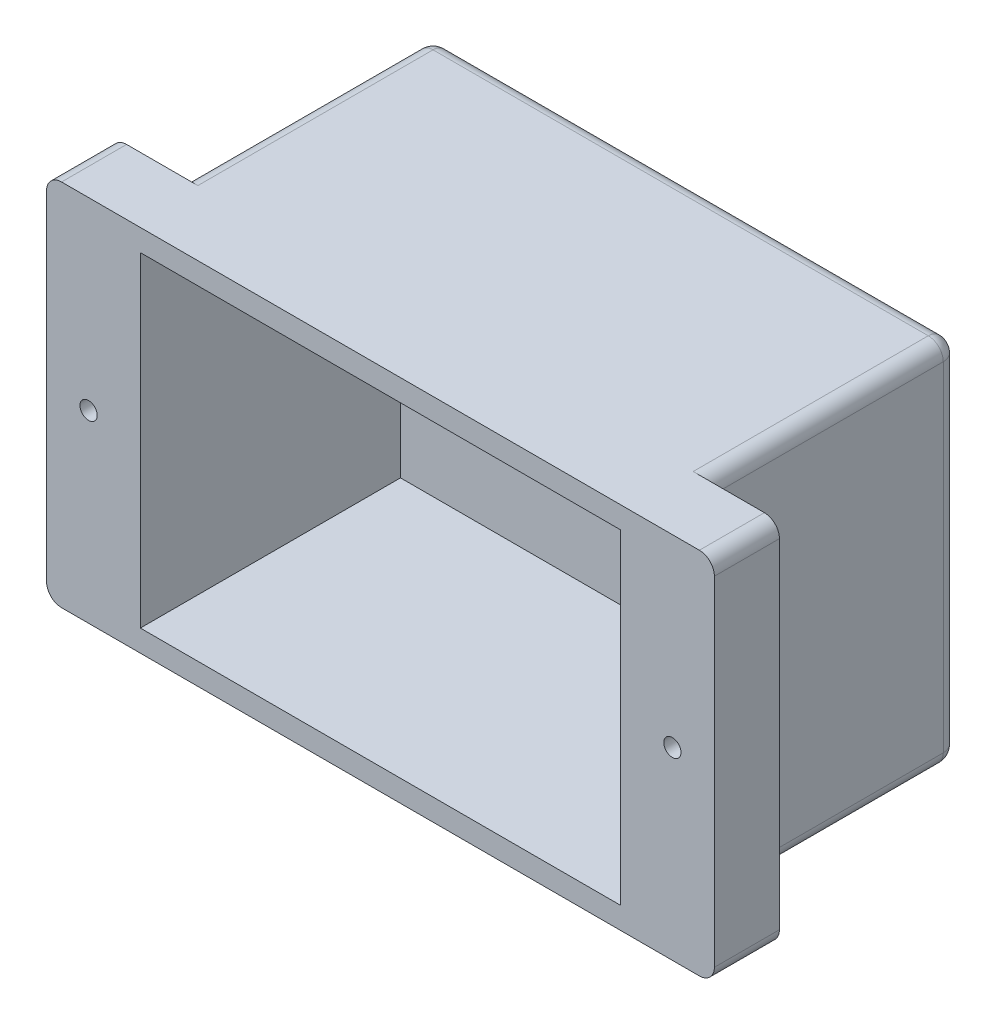
from build123d import *

# Parameters (mm, degrees)
SKETCH1_W                = 133.5
SKETCH1_H                = 73.7
SKETCH1_R                = 1.725
BOSS_EXTRUDE1_DEPTH      = 7.5
BOSS_EXTRUDE1_DEPTH_BACK = 5.5
SKETCH2_W                = 105
SKETCH2_H                = 73.7
BOSS_EXTRUDE2_DEPTH      = 50
SKETCH6_W                = 96
SKETCH6_H                = 65
CUT_EXTRUDE3_DEPTH       = 52
FILLET5_R                = 3
FILLET6_R                = 3


with BuildPart() as part:
    # Sketch1 → Boss-Extrude1 (new body, two sides)
    with BuildSketch(Plane.XY) as boss_extrude1_sk:
        Rectangle(SKETCH1_W, SKETCH1_H)
        with Locations((-58.35, 0)):
            Circle(SKETCH1_R, mode=Mode.SUBTRACT)
        with Locations((58.35, 0)):
            Circle(SKETCH1_R, mode=Mode.SUBTRACT)
    extrude(amount=BOSS_EXTRUDE1_DEPTH)
    extrude(boss_extrude1_sk.sketch, amount=-BOSS_EXTRUDE1_DEPTH_BACK)

    # Sketch2 → Boss-Extrude2 (add)
    with BuildSketch(Plane(origin=(0, 0, -5.5), x_dir=(-1, 0, 0), z_dir=(0, 0, -1))):
        Rectangle(SKETCH2_W, SKETCH2_H)
    extrude(amount=BOSS_EXTRUDE2_DEPTH)

    # Sketch6 → Cut-Extrude3 (cut)
    with BuildSketch(Plane.XY.offset(7.5)):
        Rectangle(SKETCH6_W, SKETCH6_H)
    extrude(amount=-CUT_EXTRUDE3_DEPTH, mode=Mode.SUBTRACT)

    # Fillet5
    fillet5_edges = [part.edges().sort_by_distance(p)[0] for p in [
        (-66.75, 36.85, 1),
        (66.75, 36.85, 1),
        (66.75, -36.85, 1),
        (-66.75, -36.85, 1),
    ]]
    fillet(fillet5_edges, radius=FILLET5_R)

    # Fillet6
    fillet6_edges = [part.edges().sort_by_distance(p)[0] for p in [
        (52.5, 36.85, -30.5),
        (52.5, -36.85, -30.5),
        (-52.5, -36.85, -30.5),
        (-52.5, 36.85, -30.5),
        (52.5, 0, -55.5),
        (0, -36.85, -55.5),
        (-52.5, 0, -55.5),
        (0, 36.85, -55.5),
    ]]
    fillet(fillet6_edges, radius=FILLET6_R)


solid = part.part
